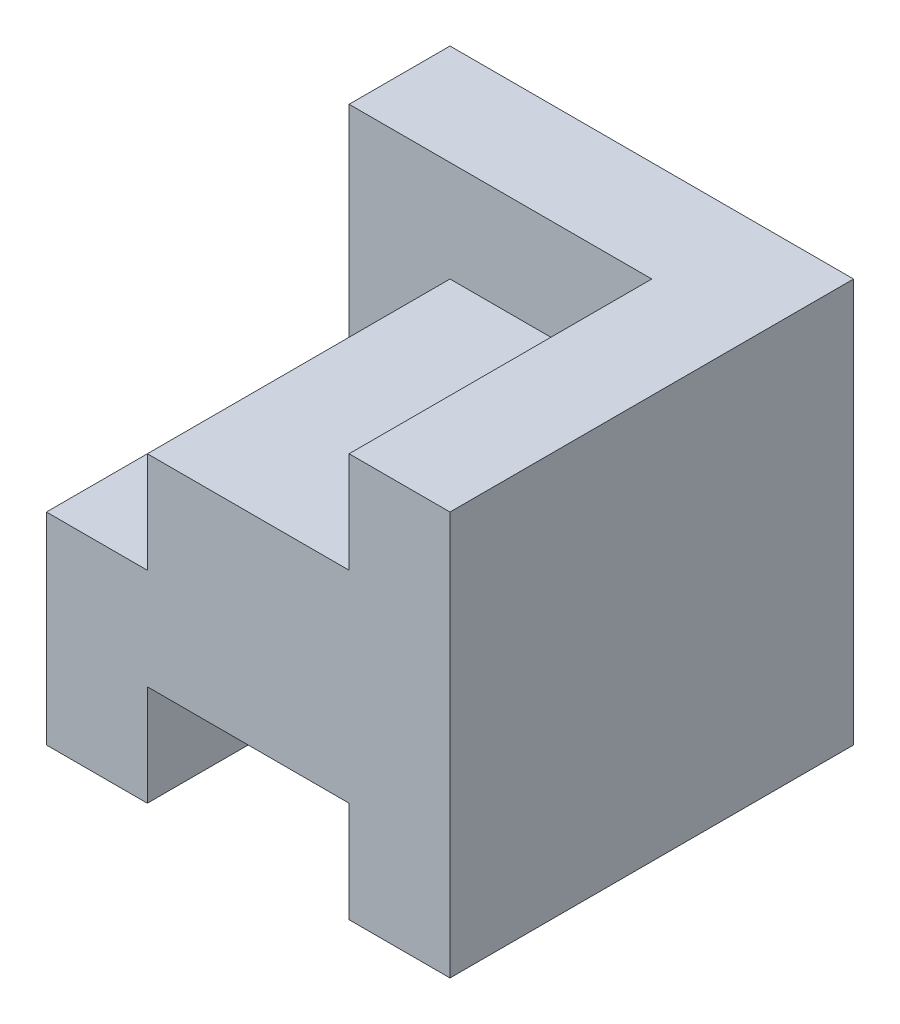
from build123d import *

# Parameters (mm, degrees)
BOSS_EXTRUDE1_DEPTH = 4
SKETCH5_W           = 3
SKETCH5_H           = 2
BOSS_EXTRUDE3_DEPTH = 1


with BuildPart() as part:
    # Sketch1 → Boss-Extrude1 (new body)
    with BuildSketch(Plane.XY):
        Polygon((0, 0), (0, 2), (1, 2), (1, 3), (3, 3), (3, 4), (4, 4), (4, 0), (3, 0), (3, 1), (1, 1), (1, 0), align=None)
    extrude(amount=BOSS_EXTRUDE1_DEPTH)

    # Sketch5 → Boss-Extrude3 (add)
    with BuildSketch(Plane(origin=(0, 0, 0), x_dir=(-1, 0, 0), z_dir=(0, 0, -1))):
        with Locations((-1.5, 3)):
            Rectangle(SKETCH5_W, SKETCH5_H)
    extrude(amount=-BOSS_EXTRUDE3_DEPTH)


solid = part.part
